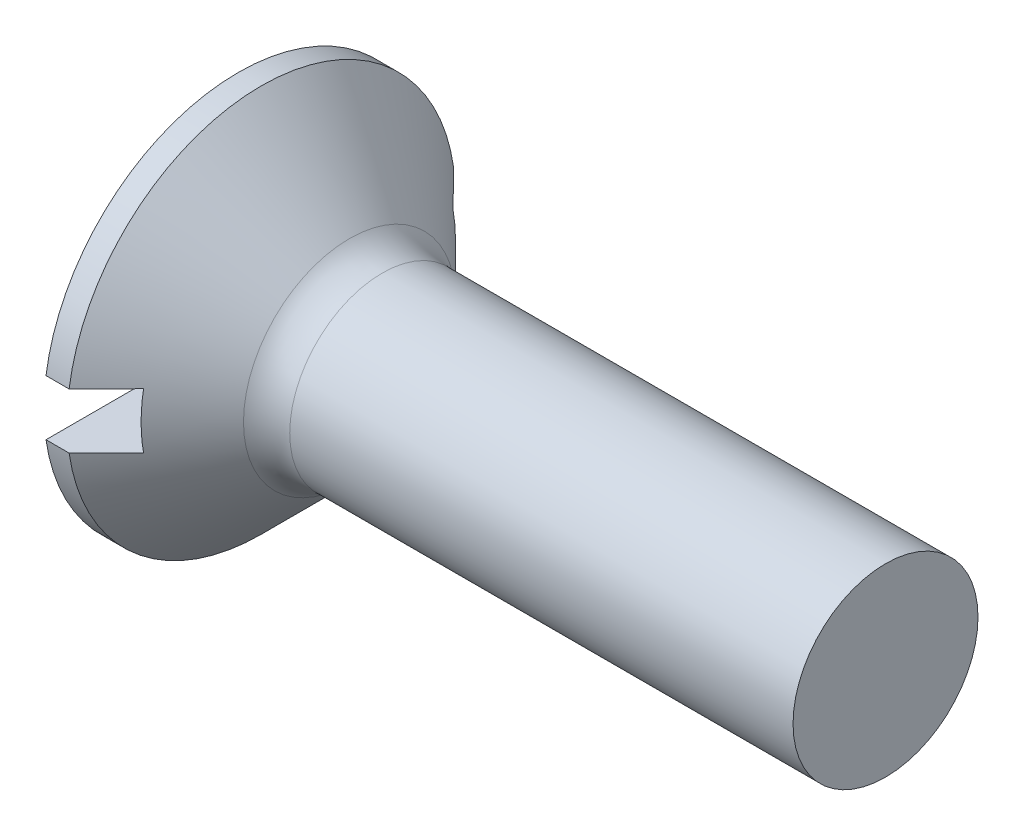
from build123d import *

# Parameters (mm, degrees)
FILLET1_R  = 1
SKETCH2_W  = 8.4
SKETCH2_H  = 1.2
SLOT_DEPTH = 1.3


with BuildPart() as part:
    # BodySke → Base-Revolve (revolve)
    with BuildSketch(Plane.XY, mode=Mode.PRIVATE) as base_revolve_sk:
        Polygon((0, 0), (0, 4.2), (0.5, 4.2), (2.7, 2), (14, 2), (14, 0), align=None)
    revolve(base_revolve_sk.sketch.rotate(Axis((-6.35, 0, 0), (1, 0, 0)), 90), axis=Axis((-6.35, 0, 0), (1, 0, 0)))  # turned: the seam where the file's is

    # Fillet1
    fillet1_edges = [part.edges().sort_by_distance(p)[0] for p in [
        (2.7, 0, -2),
    ]]
    fillet(fillet1_edges, radius=FILLET1_R)

    # Sketch2 → Slot (cut)
    with BuildSketch(Plane.ZY):
        Rectangle(SKETCH2_W, SKETCH2_H)
    extrude(amount=-SLOT_DEPTH, mode=Mode.SUBTRACT)


solid = part.part
